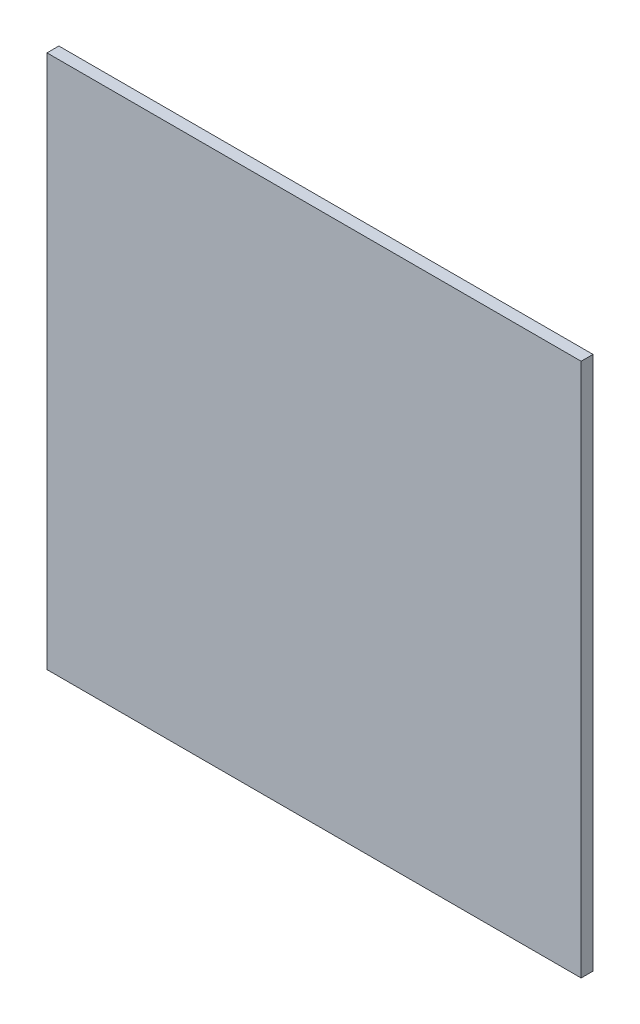
from build123d import *

# Parameters (mm, degrees)
SKETCH1_W           = 45
SKETCH1_H           = 45
BOSS_EXTRUDE1_DEPTH = 1


with BuildPart() as part:
    # Sketch1 → Boss-Extrude1 (new body)
    with BuildSketch(Plane.XY):
        Rectangle(SKETCH1_W, SKETCH1_H)
    extrude(amount=BOSS_EXTRUDE1_DEPTH)


solid = part.part
